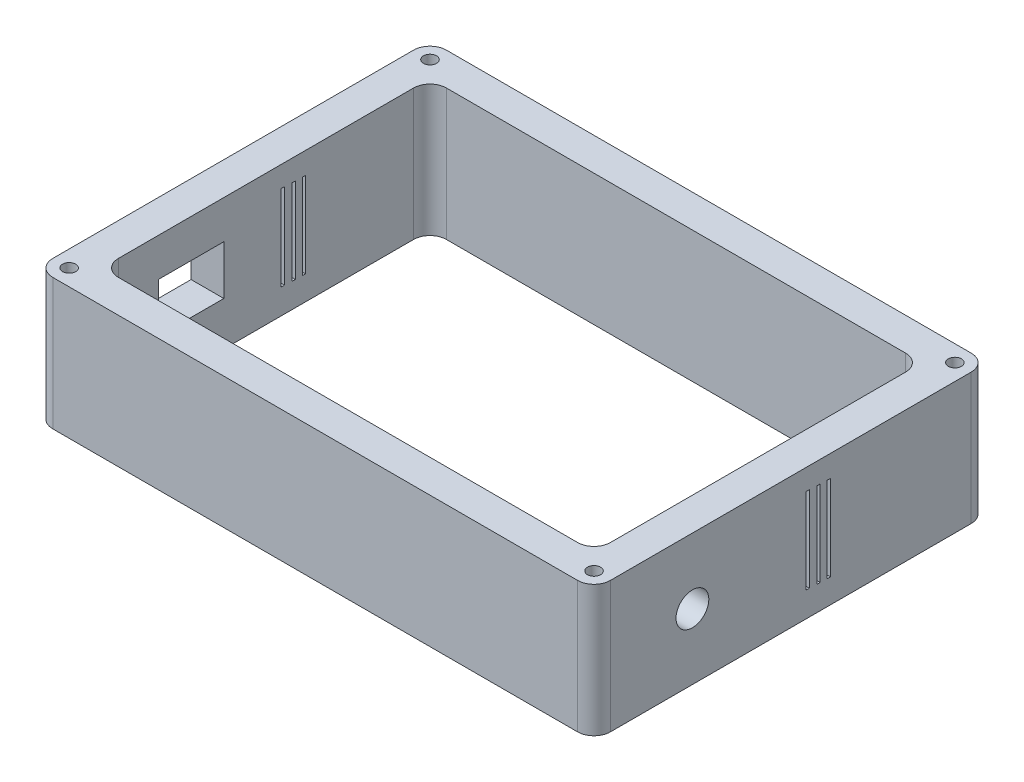
from build123d import *

# Parameters (mm, degrees)
SKETCH1_W                 = 170
SKETCH1_H                 = 120
SKETCH1_W_2               = 150
SKETCH1_H_2               = 100
EXTRUDE_THIN1_DEPTH       = 40
SKETCH2_R                 = 5
CUT_EXTRUDE1_DEPTH        = 10
F_4_0MM_DOWEL_HOLE1_D     = 4
F_4_0MM_DOWEL_HOLE1_DEPTH = 5
F_4_0MM_DOWEL_HOLE1_TIP   = 1.201721238
F_4_0MM_DOWEL_HOLE2_D     = 4
F_4_0MM_DOWEL_HOLE2_DEPTH = 5
F_4_0MM_DOWEL_HOLE2_TIP   = 1.201721238
F_4_0MM_DOWEL_HOLE3_D     = 4
F_4_0MM_DOWEL_HOLE3_DEPTH = 5
F_4_0MM_DOWEL_HOLE3_TIP   = 1.201721238
F_4_0MM_DOWEL_HOLE4_D     = 4
F_4_0MM_DOWEL_HOLE4_DEPTH = 5
F_4_0MM_DOWEL_HOLE4_TIP   = 1.201721238
SKETCH15_W                = 20
SKETCH15_H                = 15
CUT_EXTRUDE7_DEPTH        = 10
FILLET1_R                 = 5
SKETCH16_W                = 1
SKETCH16_H                = 26
CUT_EXTRUDE8_DEPTH        = 1
CUT_EXTRUDE8_DEPTH_BACK   = 171
SKETCH17_W                = 1
SKETCH17_H                = 26
CUT_EXTRUDE9_DEPTH        = 1
CUT_EXTRUDE9_DEPTH_BACK   = 171
SKETCH19_W                = 1
SKETCH19_H                = 26
CUT_EXTRUDE10_DEPTH       = 1
CUT_EXTRUDE10_DEPTH_BACK  = 171
FILLET2_R                 = 5


with BuildPart() as part:
    # Sketch1 → Extrude-Thin1 (new body)
    with BuildSketch(Plane(origin=(0, 0, 0), x_dir=(1, 0, 0), z_dir=(0, 1, 0))):
        Rectangle(SKETCH1_W, SKETCH1_H)
        Rectangle(SKETCH1_W_2, SKETCH1_H_2, mode=Mode.SUBTRACT)
    extrude(amount=EXTRUDE_THIN1_DEPTH)

    # Sketch2 → Cut-Extrude1 (cut)
    with BuildSketch(Plane(origin=(85, 0, 0), x_dir=(0, 0, -1), z_dir=(1, 0, 0))):
        with Locations((-30, 20)):
            Circle(SKETCH2_R)
    extrude(amount=-CUT_EXTRUDE1_DEPTH, mode=Mode.SUBTRACT)

    # Ø4.0mm Dowel Hole1
    with Locations(Plane(origin=(0, 40, 0), x_dir=(1, 0, 0), z_dir=(0, 1, 0))):
        with Locations((-80, 55)):
            Hole(F_4_0MM_DOWEL_HOLE1_D / 2, depth=F_4_0MM_DOWEL_HOLE1_DEPTH)
            with Locations((0, 0, -(F_4_0MM_DOWEL_HOLE1_DEPTH + F_4_0MM_DOWEL_HOLE1_TIP / 2))):  # 118° drill point
                Cone(0, F_4_0MM_DOWEL_HOLE1_D / 2, F_4_0MM_DOWEL_HOLE1_TIP, mode=Mode.SUBTRACT)

    # Ø4.0mm Dowel Hole2
    with Locations(Plane(origin=(0, 40, 0), x_dir=(1, 0, 0), z_dir=(0, 1, 0))):
        with Locations((-80, -55)):
            Hole(F_4_0MM_DOWEL_HOLE2_D / 2, depth=F_4_0MM_DOWEL_HOLE2_DEPTH)
            with Locations((0, 0, -(F_4_0MM_DOWEL_HOLE2_DEPTH + F_4_0MM_DOWEL_HOLE2_TIP / 2))):  # 118° drill point
                Cone(0, F_4_0MM_DOWEL_HOLE2_D / 2, F_4_0MM_DOWEL_HOLE2_TIP, mode=Mode.SUBTRACT)

    # Ø4.0mm Dowel Hole3
    with Locations(Plane(origin=(0, 40, 0), x_dir=(1, 0, 0), z_dir=(0, 1, 0))):
        with Locations((80, -55)):
            Hole(F_4_0MM_DOWEL_HOLE3_D / 2, depth=F_4_0MM_DOWEL_HOLE3_DEPTH)
            with Locations((0, 0, -(F_4_0MM_DOWEL_HOLE3_DEPTH + F_4_0MM_DOWEL_HOLE3_TIP / 2))):  # 118° drill point
                Cone(0, F_4_0MM_DOWEL_HOLE3_D / 2, F_4_0MM_DOWEL_HOLE3_TIP, mode=Mode.SUBTRACT)

    # Ø4.0mm Dowel Hole4
    with Locations(Plane(origin=(0, 40, 0), x_dir=(1, 0, 0), z_dir=(0, 1, 0))):
        with Locations((80, 55)):
            Hole(F_4_0MM_DOWEL_HOLE4_D / 2, depth=F_4_0MM_DOWEL_HOLE4_DEPTH)
            with Locations((0, 0, -(F_4_0MM_DOWEL_HOLE4_DEPTH + F_4_0MM_DOWEL_HOLE4_TIP / 2))):  # 118° drill point
                Cone(0, F_4_0MM_DOWEL_HOLE4_D / 2, F_4_0MM_DOWEL_HOLE4_TIP, mode=Mode.SUBTRACT)

    # Sketch15 → Cut-Extrude7 (cut)
    with BuildSketch(Plane.ZY.offset(85)):
        with Locations((22.837644719, 20.840649499)):
            Rectangle(SKETCH15_W, SKETCH15_H)
    extrude(amount=-CUT_EXTRUDE7_DEPTH, mode=Mode.SUBTRACT)

    # Fillet1
    fillet1_edges = [part.edges().sort_by_distance(p)[0] for p in [
        (85, 20, 60),
        (-85, 20, 60),
        (-85, 20, -60),
        (85, 20, -60),
    ]]
    fillet(fillet1_edges, radius=FILLET1_R)

    # Sketch16 → Cut-Extrude8 (cut, two sides)
    with BuildSketch(Plane(origin=(85, 0, 0), x_dir=(0, 0, -1), z_dir=(1, 0, 0))) as cut_extrude8_sk:
        with Locations((5.123572244, 20.634211022)):
            Rectangle(SKETCH16_W, SKETCH16_H)
    extrude(amount=CUT_EXTRUDE8_DEPTH, mode=Mode.SUBTRACT)
    extrude(cut_extrude8_sk.sketch, amount=-CUT_EXTRUDE8_DEPTH_BACK, mode=Mode.SUBTRACT)

    # Sketch17 → Cut-Extrude9 (cut, two sides)
    with BuildSketch(Plane(origin=(85, 0, 0), x_dir=(0, 0, -1), z_dir=(1, 0, 0))) as cut_extrude9_sk:
        with Locations((8.466927988, 20.476753878)):
            Rectangle(SKETCH17_W, SKETCH17_H)
    extrude(amount=CUT_EXTRUDE9_DEPTH, mode=Mode.SUBTRACT)
    extrude(cut_extrude9_sk.sketch, amount=-CUT_EXTRUDE9_DEPTH_BACK, mode=Mode.SUBTRACT)

    # Sketch19 → Cut-Extrude10 (cut, two sides)
    with BuildSketch(Plane(origin=(85, 0, 0), x_dir=(0, 0, -1), z_dir=(1, 0, 0))) as cut_extrude10_sk:
        with Locations((11.568551735, 20.390257517)):
            Rectangle(SKETCH19_W, SKETCH19_H)
    extrude(amount=CUT_EXTRUDE10_DEPTH, mode=Mode.SUBTRACT)
    extrude(cut_extrude10_sk.sketch, amount=-CUT_EXTRUDE10_DEPTH_BACK, mode=Mode.SUBTRACT)

    # Fillet2
    fillet2_edges = [part.edges().sort_by_distance(p)[0] for p in [
        (75, 20, 50),
        (75, 20, -50),
        (-75, 20, -50),
        (-75, 20, 50),
    ]]
    fillet(fillet2_edges, radius=FILLET2_R)


solid = part.part
